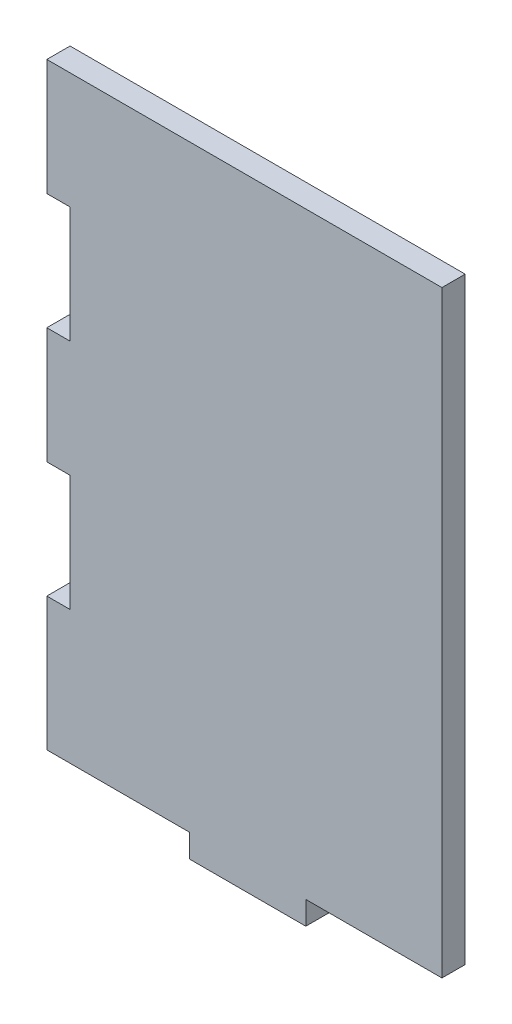
from build123d import *

# Parameters (mm, degrees)
SKIZZE1_W                       = 34.00858099
SKIZZE1_H                       = 51.467136578
AUFSATZ_LINEAR_AUSTRAGEN1_DEPTH = 2
SKIZZE6_W                       = 10
SKIZZE6_H                       = 2
AUFSATZ_LINEAR_AUSTRAGEN2_DEPTH = 2
SKIZZE7_W                       = 2
SKIZZE7_H                       = 10
SCHNITT_LINEAR_AUSTRAGEN1_DEPTH = 2
SKIZZE8_W                       = 2
SKIZZE8_H                       = 10
SCHNITT_LINEAR_AUSTRAGEN2_DEPTH = 2


with BuildPart() as part:
    # Skizze1 → Aufsatz-Linear austragen1 (new body)
    with BuildSketch(Plane.XY):
        Rectangle(SKIZZE1_W, SKIZZE1_H)
    extrude(amount=AUFSATZ_LINEAR_AUSTRAGEN1_DEPTH)

    # Skizze6 → Aufsatz-Linear austragen2 (add)
    with BuildSketch(Plane.XZ.offset(25.733568289)):
        with Locations((0.286784859, 1)):
            Rectangle(SKIZZE6_W, SKIZZE6_H)
    extrude(amount=AUFSATZ_LINEAR_AUSTRAGEN2_DEPTH)

    # Skizze7 → Schnitt-Linear austragen1 (cut)
    with BuildSketch(Plane.ZY.offset(17.004290495)):
        with Locations((1, 10.733568289)):
            Rectangle(SKIZZE7_W, SKIZZE7_H)
    extrude(amount=-SCHNITT_LINEAR_AUSTRAGEN1_DEPTH, mode=Mode.SUBTRACT)

    # Skizze8 → Schnitt-Linear austragen2 (cut)
    with BuildSketch(Plane.ZY.offset(17.004290495)):
        with Locations((1, -9.266431711)):
            Rectangle(SKIZZE8_W, SKIZZE8_H)
    extrude(amount=-SCHNITT_LINEAR_AUSTRAGEN2_DEPTH, mode=Mode.SUBTRACT)


solid = part.part
